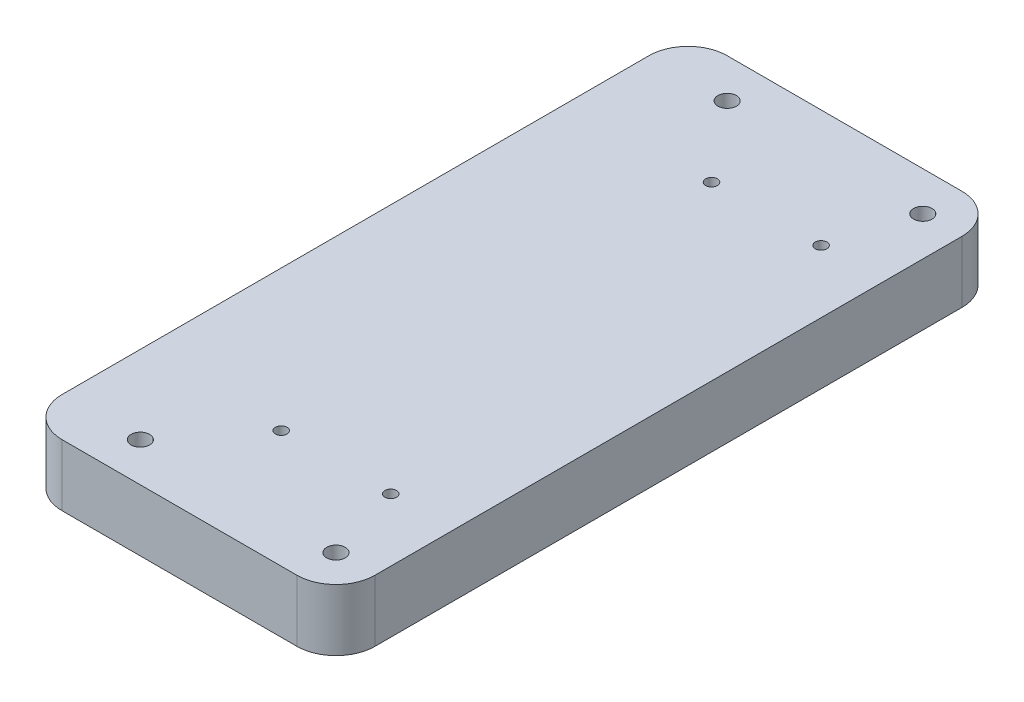
from build123d import *

# Parameters (mm, degrees)
SKETCH1_W           = 101.6
SKETCH1_H           = 215.9
BOSS_EXTRUDE2_DEPTH = 20
FILLET1_R           = 12.7
SKETCH5_R           = 3
CUT_EXTRUDE1_DEPTH  = 21
SKETCH7_R           = 1.905
CUT_EXTRUDE2_DEPTH  = 21


with BuildPart() as part:
    # Sketch1 → Boss-Extrude2 (new body)
    with BuildSketch(Plane(origin=(0, 0, 0), x_dir=(1, 0, 0), z_dir=(0, 1, 0))):
        with Locations((50.8, 107.95)):
            Rectangle(SKETCH1_W, SKETCH1_H)
    extrude(amount=BOSS_EXTRUDE2_DEPTH)

    # Fillet1
    fillet1_edges = [part.edges().sort_by_distance(p)[0] for p in [
        (0, 10, -215.9),
        (101.6, 10, -215.9),
        (101.6, 10, 0),
        (0, 10, 0),
    ]]
    fillet(fillet1_edges, radius=FILLET1_R)

    # Sketch5 → Cut-Extrude1 (cut, through all)
    with BuildSketch(Plane(origin=(0, 0, 0), x_dir=(-1, 0, 0), z_dir=(0, -1, 0))):
        with Locations((-88.9, 203.2)):
            Circle(SKETCH5_R)
        with Locations((-25.4, 203.2)):
            Circle(SKETCH5_R)
        with Locations((-88.9, 12.7)):
            Circle(SKETCH5_R)
        with Locations((-25.4, 12.7)):
            Circle(SKETCH5_R)
    extrude(amount=-CUT_EXTRUDE1_DEPTH, mode=Mode.SUBTRACT)

    # Sketch7 → Cut-Extrude2 (cut, through all)
    with BuildSketch(Plane(origin=(0, 20, 0), x_dir=(1, 0, 0), z_dir=(0, 1, 0))):
        with Locations((81.28, 177.8)):
            Circle(SKETCH7_R)
        with Locations((45.72, 177.8)):
            Circle(SKETCH7_R)
        with Locations((45.72, 38.1)):
            Circle(SKETCH7_R)
        with Locations((81.28, 38.1)):
            Circle(SKETCH7_R)
    extrude(amount=-CUT_EXTRUDE2_DEPTH, mode=Mode.SUBTRACT)


solid = part.part
